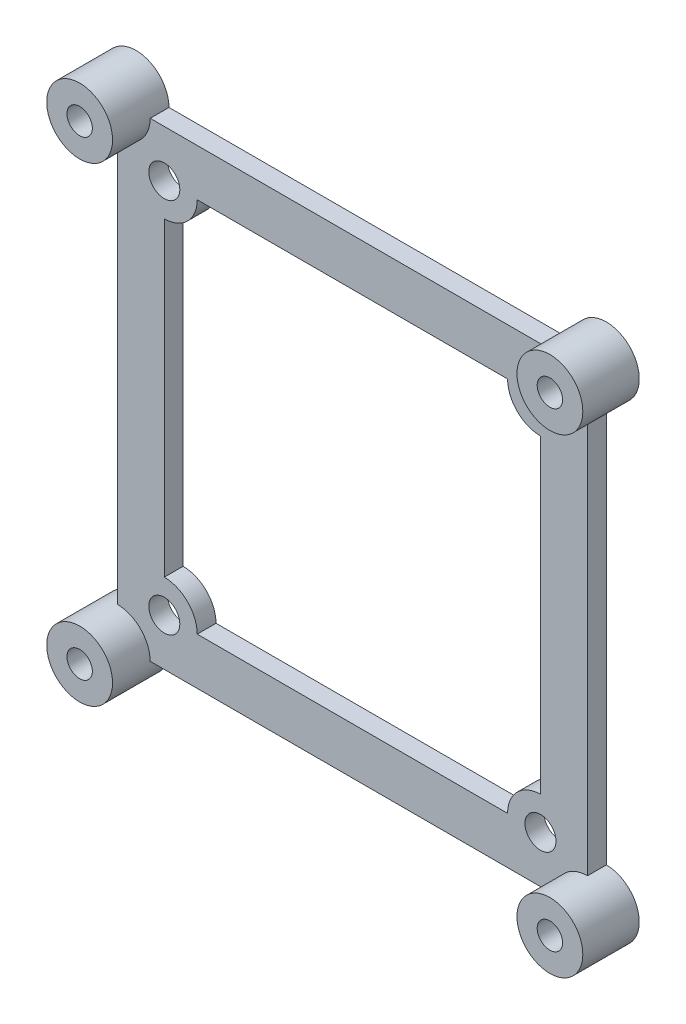
from build123d import *

# Parameters (mm, degrees)
SKETCH1_R           = 1.65
BOSS_EXTRUDE1_DEPTH = 2
SKETCH2_R           = 3.5
SKETCH2_R_2         = 1.65
SKETCH2_R_3         = 1.570665428
BOSS_EXTRUDE2_DEPTH = 4
EXTRUDE_THIN1_START = -6
SKETCH3_R           = 1.75
SKETCH3_R_2         = 1.35
EXTRUDE_THIN1_DEPTH = 6


with BuildPart() as part:
    # Sketch1 → Boss-Extrude1 (new body)
    with BuildSketch(Plane.XY):
        with BuildLine():
            Line((-21.5, 25), (21.5, 25))
            ThreePointArc((21.5, 25), (27.474873734, 27.474873734), (25, 21.5))
            Line((25, 21.5), (25, -21.5))
            ThreePointArc((25, -21.5), (27.474873734, -27.474873734), (21.5, -25))
            Line((21.5, -25), (-21.5, -25))
            ThreePointArc((-21.5, -25), (-27.474873734, -27.474873734), (-25, -21.5))
            Line((-25, -21.5), (-25, 21.5))
            ThreePointArc((-25, 21.5), (-27.474873734, 27.474873734), (-21.5, 25))
        make_face()
        with Locations((-20, 20)):
            Circle(SKETCH1_R, mode=Mode.SUBTRACT)
        with Locations((-25, 25)):
            Circle(SKETCH1_R, mode=Mode.SUBTRACT)
        with Locations((20, 20)):
            Circle(SKETCH1_R, mode=Mode.SUBTRACT)
        with Locations((25, 25)):
            Circle(SKETCH1_R, mode=Mode.SUBTRACT)
        with Locations((25, -25)):
            Circle(SKETCH1_R, mode=Mode.SUBTRACT)
        with Locations((20, -20)):
            Circle(SKETCH1_R, mode=Mode.SUBTRACT)
        with Locations((-20, -20)):
            Circle(SKETCH1_R, mode=Mode.SUBTRACT)
        with Locations((-25, -25)):
            Circle(SKETCH1_R, mode=Mode.SUBTRACT)
        with BuildLine():
            Line((-16.5, 20), (16.5, 20))
            ThreePointArc((16.5, 20), (17.525126266, 17.525126266), (20, 16.5))
            Line((20, 16.5), (20, -16.5))
            ThreePointArc((20, -16.5), (17.525126266, -17.525126266), (16.5, -20))
            Line((16.5, -20), (-16.5, -20))
            ThreePointArc((-16.5, -20), (-17.525126266, -17.525126266), (-20, -16.5))
            Line((-20, -16.5), (-20, 16.5))
            ThreePointArc((-20, 16.5), (-17.525126266, 17.525126266), (-16.5, 20))
        make_face(mode=Mode.SUBTRACT)
    extrude(amount=BOSS_EXTRUDE1_DEPTH)

    # Sketch2 → Boss-Extrude2 (add)
    with BuildSketch(Plane.XY.offset(2)):
        with Locations((-25, 25)):
            Circle(SKETCH2_R)
        with Locations((-25, 25)):
            Circle(SKETCH2_R_2, mode=Mode.SUBTRACT)
        with Locations((25, 25)):
            Circle(SKETCH2_R)
        with Locations((25, 25)):
            Circle(SKETCH2_R_3, mode=Mode.SUBTRACT)
        with Locations((-25, -25)):
            Circle(SKETCH2_R)
        with Locations((-25, -25)):
            Circle(SKETCH2_R_2, mode=Mode.SUBTRACT)
        with Locations((25, -25)):
            Circle(SKETCH2_R)
        with Locations((25, -25)):
            Circle(SKETCH2_R_2, mode=Mode.SUBTRACT)
    extrude(amount=BOSS_EXTRUDE2_DEPTH)

    # Sketch3 → Extrude-Thin1 (add)
    with BuildSketch(Plane.XY.offset(6).offset(EXTRUDE_THIN1_START)):
        with Locations((-25, 25)):
            Circle(SKETCH3_R)
        with Locations((-25, 25)):
            Circle(SKETCH3_R_2, mode=Mode.SUBTRACT)
        with Locations((25, 25)):
            Circle(SKETCH3_R)
        with Locations((25, 25)):
            Circle(SKETCH3_R_2, mode=Mode.SUBTRACT)
        with Locations((25, -25)):
            Circle(SKETCH3_R)
        with Locations((25, -25)):
            Circle(SKETCH3_R_2, mode=Mode.SUBTRACT)
        with Locations((-25, -25)):
            Circle(SKETCH3_R)
        with Locations((-25, -25)):
            Circle(SKETCH3_R_2, mode=Mode.SUBTRACT)
    extrude(amount=EXTRUDE_THIN1_DEPTH)


solid = part.part
